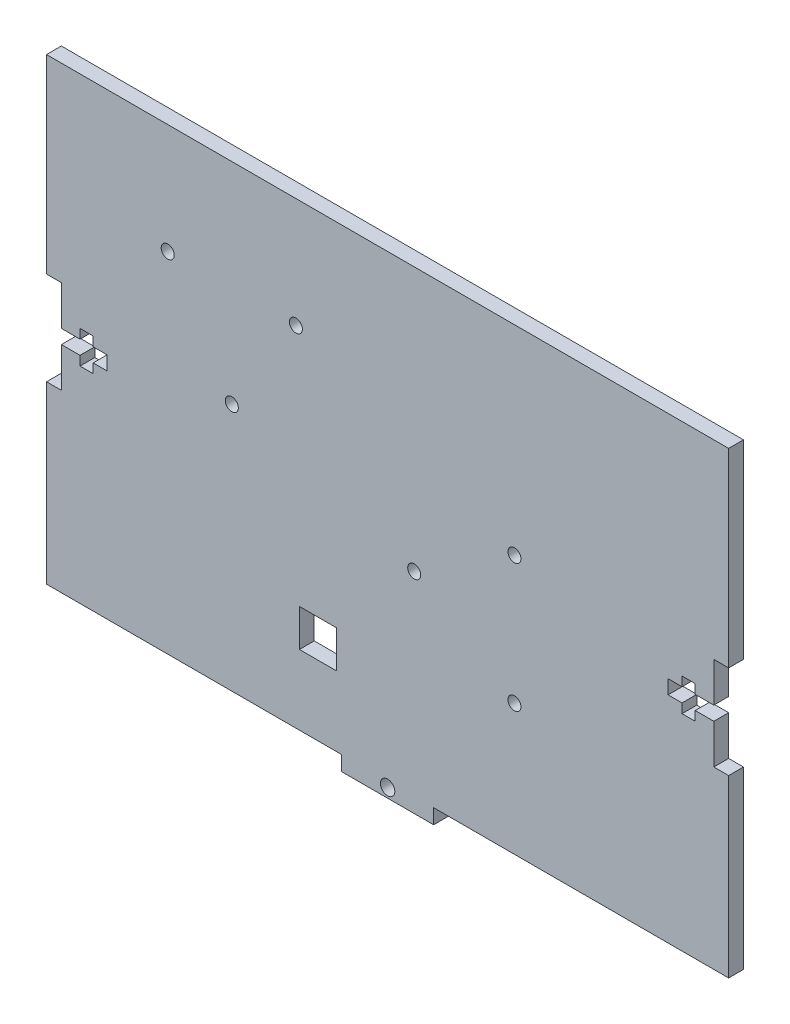
from build123d import *

# Parameters (mm, degrees)
SKETCH1_W               = 146.36
SKETCH1_H               = 101.6
BOSS_EXTRUDE1_DEPTH     = 3.18
CUT_EXTRUDE1_START      = -4.18
SKETCH2_W               = 3.18
SKETCH2_H               = 20
SKETCH2_W_2             = 13
SKETCH2_H_2             = 3
SKETCH2_W_3             = 2.82
SKETCH2_H_3             = 7
CUT_EXTRUDE1_DEPTH      = 5.18
CUT_EXTRUDE2_START      = -4.18
SKETCH3_W               = 63.305
SKETCH3_H               = 3.18
CUT_EXTRUDE2_DEPTH      = 5.18
SKETCH4_R               = 1.55
CUT_EXTRUDE3_DEPTH      = 1
CUT_EXTRUDE3_DEPTH_BACK = 4.18
SKETCH9_W               = 8
SKETCH9_H               = 8
CUT_EXTRUDE7_DEPTH      = 1
CUT_EXTRUDE7_DEPTH_BACK = 4.18
SKETCH8_R               = 1.4
CUT_EXTRUDE8_DEPTH      = 1
CUT_EXTRUDE8_DEPTH_BACK = 4.18
SKETCH12_R              = 1.4
CUT_EXTRUDE9_DEPTH      = 1
CUT_EXTRUDE9_DEPTH_BACK = 4.18


with BuildPart() as part:
    # Sketch1 → Boss-Extrude1 (new body)
    with BuildSketch(Plane.XY):
        Rectangle(SKETCH1_W, SKETCH1_H)
    extrude(amount=BOSS_EXTRUDE1_DEPTH)

    # Sketch2 → Cut-Extrude1 (cut)
    with BuildSketch(Plane.XY.offset(3.18).offset(CUT_EXTRUDE1_START)):
        with Locations((-71.59, 0)):
            Rectangle(SKETCH2_W, SKETCH2_H)
        with Locations((-66.68, 0)):
            Rectangle(SKETCH2_W_2, SKETCH2_H_2)
        with Locations((-64.59, 0)):
            Rectangle(SKETCH2_W_3, SKETCH2_H_3)
    cut_extrude1 = extrude(amount=CUT_EXTRUDE1_DEPTH, mode=Mode.SUBTRACT)

    # Mirror1: Cut-Extrude1 across plane
    add(cut_extrude1.mirror(Plane(origin=(0, 0, 0), x_dir=(0, 0, 1), z_dir=(1, 0, 0))), mode=Mode.SUBTRACT)

    # Sketch3 → Cut-Extrude2 (cut)
    with BuildSketch(Plane.XY.offset(3.18).offset(CUT_EXTRUDE2_START)):
        with Locations((-41.5275, -49.21)):
            Rectangle(SKETCH3_W, SKETCH3_H)
    cut_extrude2 = extrude(amount=CUT_EXTRUDE2_DEPTH, mode=Mode.SUBTRACT)

    # Mirror2: Cut-Extrude2 across plane
    add(cut_extrude2.mirror(Plane(origin=(0, 0, 0), x_dir=(0, 0, 1), z_dir=(1, 0, 0))), mode=Mode.SUBTRACT)

    # Sketch4 → Cut-Extrude3 (cut, two sides)
    with BuildSketch(Plane.XY.offset(3.18)) as cut_extrude3_sk:
        with Locations((0, -48.8)):
            Circle(SKETCH4_R)
    extrude(amount=CUT_EXTRUDE3_DEPTH, mode=Mode.SUBTRACT)
    extrude(cut_extrude3_sk.sketch, amount=-CUT_EXTRUDE3_DEPTH_BACK, mode=Mode.SUBTRACT)

    # Sketch9 → Cut-Extrude7 (cut, two sides)
    with BuildSketch(Plane(origin=(0, 0, 0), x_dir=(-1, 0, 0), z_dir=(0, 0, -1))) as cut_extrude7_sk:
        with Locations((14.920568418, -28.62)):
            Rectangle(SKETCH9_W, SKETCH9_H)
    extrude(amount=CUT_EXTRUDE7_DEPTH, mode=Mode.SUBTRACT)
    extrude(cut_extrude7_sk.sketch, amount=-CUT_EXTRUDE7_DEPTH_BACK, mode=Mode.SUBTRACT)

    # Sketch8 → Cut-Extrude8 (cut, two sides)
    with BuildSketch(Plane(origin=(0, 0, 0), x_dir=(-1, 0, 0), z_dir=(0, 0, -1))) as cut_extrude8_sk:
        with Locations((-5.716117592, -5.795275692)):
            Circle(SKETCH8_R)
        with Locations((-27.216117592, 7.954724308)):
            Circle(SKETCH8_R)
        with Locations((-27.216117592, -19.545275692)):
            Circle(SKETCH8_R)
    extrude(amount=CUT_EXTRUDE8_DEPTH, mode=Mode.SUBTRACT)
    extrude(cut_extrude8_sk.sketch, amount=-CUT_EXTRUDE8_DEPTH_BACK, mode=Mode.SUBTRACT)

    # Sketch12 → Cut-Extrude9 (cut, two sides)
    with BuildSketch(Plane(origin=(0, 0, 0), x_dir=(-1, 0, 0), z_dir=(0, 0, -1))) as cut_extrude9_sk:
        with Locations((19.68, 27.2)):
            Circle(SKETCH12_R)
        with Locations((33.43, 5.7)):
            Circle(SKETCH12_R)
        with Locations((47.18, 27.2)):
            Circle(SKETCH12_R)
    extrude(amount=CUT_EXTRUDE9_DEPTH, mode=Mode.SUBTRACT)
    extrude(cut_extrude9_sk.sketch, amount=-CUT_EXTRUDE9_DEPTH_BACK, mode=Mode.SUBTRACT)


solid = part.part
